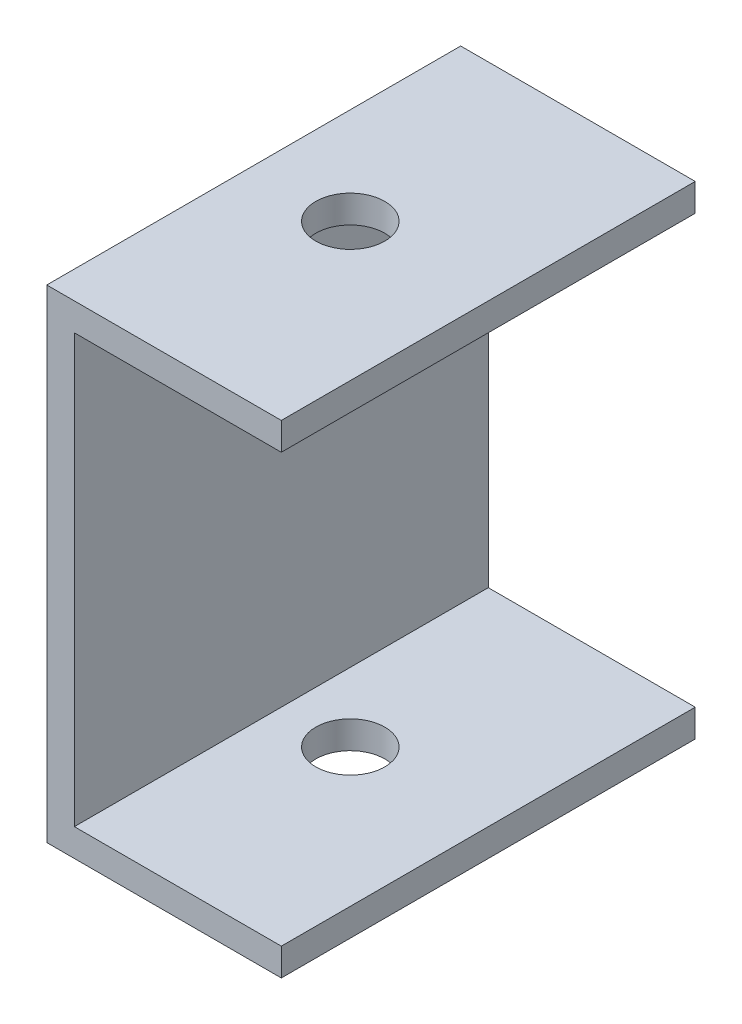
from build123d import *

# Parameters (mm, degrees)
BOSS_EXTRUDE1_DEPTH = 30
SKETCH2_R           = 2.5
CUT_EXTRUDE1_DEPTH  = 10
SKETCH3_R           = 2.5
CUT_EXTRUDE2_DEPTH  = 10
SKETCH4_W           = 2
SKETCH4_H           = 30
BOSS_EXTRUDE2_DEPTH = 5
SKETCH5_W           = 17
SKETCH5_H           = 30
BOSS_EXTRUDE3_DEPTH = 2
SKETCH6_R           = 2.5
CUT_EXTRUDE3_DEPTH  = 2


with BuildPart() as part:
    # Sketch1 → Boss-Extrude1 (new body)
    with BuildSketch(Plane.XY):
        Polygon((0, 0), (0, 28), (2, 28), (2, 2), (17, 2), (17, 0), align=None)
    extrude(amount=BOSS_EXTRUDE1_DEPTH)

    # Sketch2 → Cut-Extrude1 (cut)
    with BuildSketch(Plane(origin=(0, 2, 0), x_dir=(1, 0, 0), z_dir=(0, 1, 0))):
        with Locations((7, -15)):
            Circle(SKETCH2_R)
    extrude(amount=-CUT_EXTRUDE1_DEPTH, mode=Mode.SUBTRACT)

    # Sketch3 → Cut-Extrude2 (cut)
    with BuildSketch(Plane(origin=(2, 0, 0), x_dir=(0, 0, -1), z_dir=(1, 0, 0))):
        with Locations((-15, 23)):
            Circle(SKETCH3_R)
    extrude(amount=-CUT_EXTRUDE2_DEPTH, mode=Mode.SUBTRACT)

    # Sketch4 → Boss-Extrude2 (add)
    with BuildSketch(Plane(origin=(0, 28, 0), x_dir=(1, 0, 0), z_dir=(0, 1, 0))):
        with Locations((1, -15)):
            Rectangle(SKETCH4_W, SKETCH4_H)
    extrude(amount=BOSS_EXTRUDE2_DEPTH)

    # Sketch5 → Boss-Extrude3 (add)
    with BuildSketch(Plane(origin=(0, 33, 0), x_dir=(1, 0, 0), z_dir=(0, 1, 0))):
        with Locations((8.5, -15)):
            Rectangle(SKETCH5_W, SKETCH5_H)
    extrude(amount=BOSS_EXTRUDE3_DEPTH)

    # Sketch6 → Cut-Extrude3 (cut)
    with BuildSketch(Plane.XZ.offset(-33)):
        with Locations((7, 15)):
            Circle(SKETCH6_R)
    extrude(amount=-CUT_EXTRUDE3_DEPTH, mode=Mode.SUBTRACT)


solid = part.part
